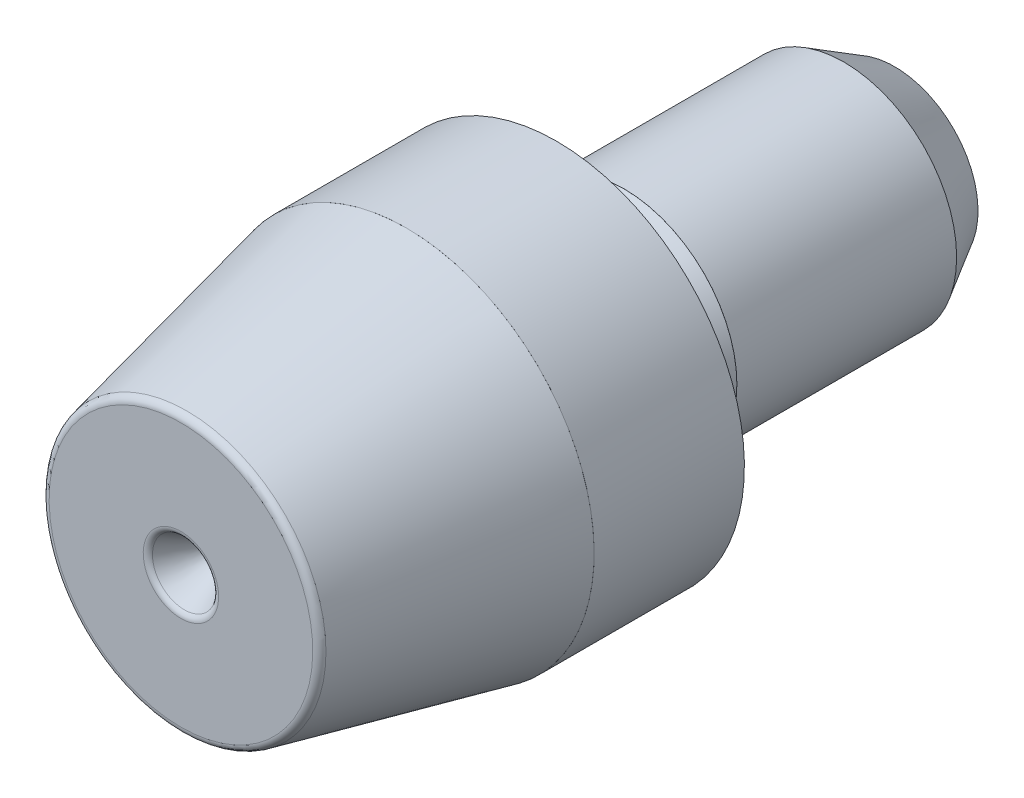
from build123d import *

# Parameters (mm, degrees)
SKETCH10_R          = 0.9
CUT_EXTRUDE2_DEPTH  = 1.5
CUT_EXTRUDE2_TAPER  = 30
SKETCH15_R          = 0.9
CUT_EXTRUDE5_DEPTH  = 1.5
CUT_EXTRUDE5_TAPER  = 30
FILLET1_R           = 0.2
FILLET3_R           = 0.18
SKETCH17_R          = 5.001
SKETCH17_R_2        = 5
BOSS_EXTRUDE1_DEPTH = 4
SKETCH19_R          = 3.001
SKETCH19_R_2        = 3
BOSS_EXTRUDE2_DEPTH = 5.85


with BuildPart() as part:
    # Sketch3 → Revolve2 (revolve)
    with BuildSketch(Plane(origin=(0, 0, 0), x_dir=(0, 0, -1), z_dir=(1, 0, 0))):
        Polygon((-9.5, 0), (-9.5, 3.669832024), (-3.5, 5), (0.5, 5), (0.5, 3), (9.5, 3), (9.5, 0), align=None)
    revolve(axis=Axis((0, 0, -9.5), (0, 0, 1)))

    # Sketch16 → Cut-Revolve1 (revolve, cut)
    with BuildSketch(Plane(origin=(0, 0, 0), x_dir=(0, 0, -1), z_dir=(1, 0, 0))):
        with BuildLine():
            Line((0.5, 3), (0.391746825, 2.8125))
            ThreePointArc((0.391746825, 2.8125), (0.391746825, 2.6875), (0.5, 2.625))
            Line((0.5, 2.625), (1.137450732, 2.625))
            ThreePointArc((1.137450732, 2.625), (1.267686865, 2.636394185), (1.39396584, 2.670230534))
            Line((1.39396584, 2.670230534), (2.3, 3))
            Line((2.3, 3), (0.5, 3))
        make_face()
        Polygon((8.15, 3), (9.5, 2.220577137), (9.5, 3), align=None)
    revolve(axis=Axis((0, 0, 9.5), (0, 0, -1)), mode=Mode.SUBTRACT)

    # Sketch10 → Cut-Extrude2 (cut)
    with BuildSketch(Plane.XY.offset(9.5)):
        Circle(SKETCH10_R)
    extrude(amount=-CUT_EXTRUDE2_DEPTH, taper=CUT_EXTRUDE2_TAPER, mode=Mode.SUBTRACT)

    # Sketch15 → Cut-Extrude5 (cut)
    with BuildSketch(Plane(origin=(0, 0, -9.5), x_dir=(-1, 0, 0), z_dir=(0, 0, -1))):
        Circle(SKETCH15_R)
    extrude(amount=-CUT_EXTRUDE5_DEPTH, taper=CUT_EXTRUDE5_TAPER, mode=Mode.SUBTRACT)

    # Fillet1
    fillet1_edges = [part.edges().sort_by_distance(p)[0] for p in [
        (0, -3.669832024, 9.5),
    ]]
    fillet(fillet1_edges, radius=FILLET1_R)

    # Fillet3
    fillet3_edges = [part.edges().sort_by_distance(p)[0] for p in [
        (-0.9, 0, 9.5),
        (0.9, 0, -9.5),
    ]]
    fillet(fillet3_edges, radius=FILLET3_R)


with BuildPart() as body_2:
    # Sketch17 → Boss-Extrude1 (new body)
    with BuildSketch(Plane(origin=(0, 0, -0.5), x_dir=(-1, 0, 0), z_dir=(0, 0, -1))):
        Circle(SKETCH17_R)
        Circle(SKETCH17_R_2, mode=Mode.SUBTRACT)
    extrude(amount=-BOSS_EXTRUDE1_DEPTH)


with BuildPart() as body_3:
    # Sketch19 → Boss-Extrude2 (new body)
    with BuildSketch(Plane(origin=(0, 0, -8.15), x_dir=(-1, 0, 0), z_dir=(0, 0, -1))):
        Circle(SKETCH19_R)
        Circle(SKETCH19_R_2, mode=Mode.SUBTRACT)
    extrude(amount=-BOSS_EXTRUDE2_DEPTH)


solid = Compound([part.part, body_2.part, body_3.part])
